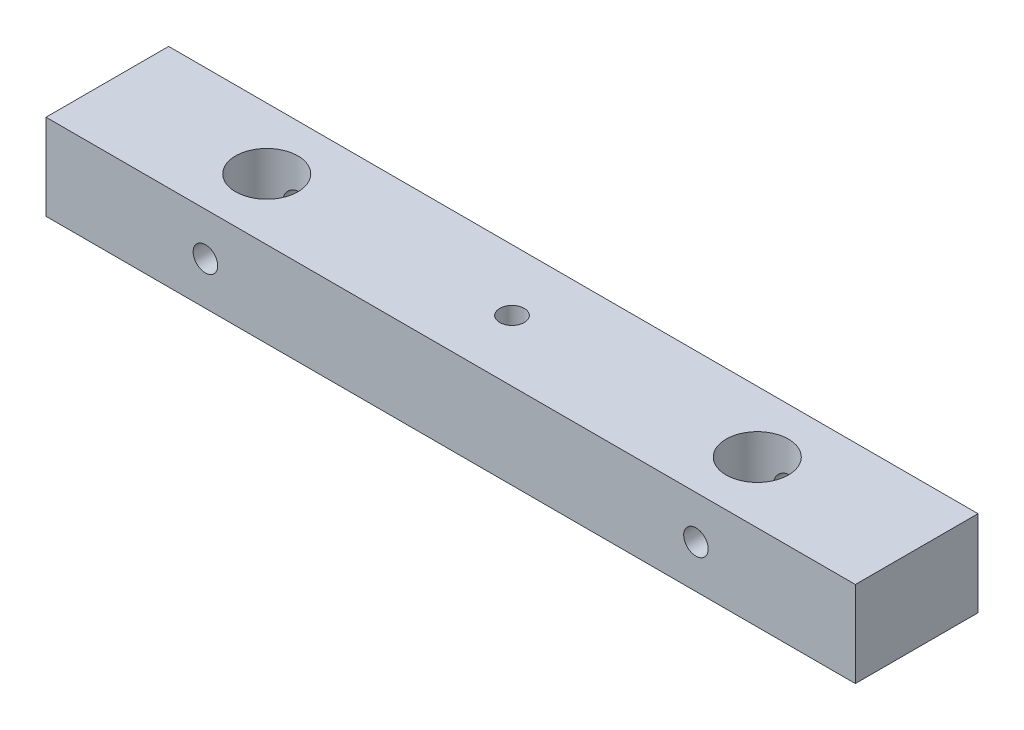
from build123d import *

# Parameters (mm, degrees)
SKETCH1_W           = 330
SKETCH1_H           = 50
BOSS_EXTRUDE1_DEPTH = 35
SKETCH2_R           = 12.7
CUT_EXTRUDE1_DEPTH  = 70
SKETCH3_R           = 5
CUT_EXTRUDE2_DEPTH  = 70
SKETCH4_R           = 5
CUT_EXTRUDE3_DEPTH  = 43


with BuildPart() as part:
    # Sketch1 → Boss-Extrude1 (new body)
    with BuildSketch(Plane(origin=(0, 0, 0), x_dir=(1, 0, 0), z_dir=(0, 1, 0))):
        Rectangle(SKETCH1_W, SKETCH1_H)
    extrude(amount=BOSS_EXTRUDE1_DEPTH)

    # Sketch2 → Cut-Extrude1 (cut)
    with BuildSketch(Plane(origin=(0, 35, 0), x_dir=(1, 0, 0), z_dir=(0, 1, 0))):
        with Locations((-100, 0)):
            Circle(SKETCH2_R)
        with Locations((100, 0)):
            Circle(SKETCH2_R)
    extrude(amount=-CUT_EXTRUDE1_DEPTH, mode=Mode.SUBTRACT)

    # Sketch3 → Cut-Extrude2 (cut)
    with BuildSketch(Plane.XY.offset(25)):
        with Locations((-100, 17.5)):
            Circle(SKETCH3_R)
        with Locations((100, 17.5)):
            Circle(SKETCH3_R)
    extrude(amount=-CUT_EXTRUDE2_DEPTH, mode=Mode.SUBTRACT)

    # Sketch4 → Cut-Extrude3 (cut)
    with BuildSketch(Plane(origin=(0, 35, 0), x_dir=(1, 0, 0), z_dir=(0, 1, 0))):
        Circle(SKETCH4_R)
    extrude(amount=-CUT_EXTRUDE3_DEPTH, mode=Mode.SUBTRACT)


solid = part.part
